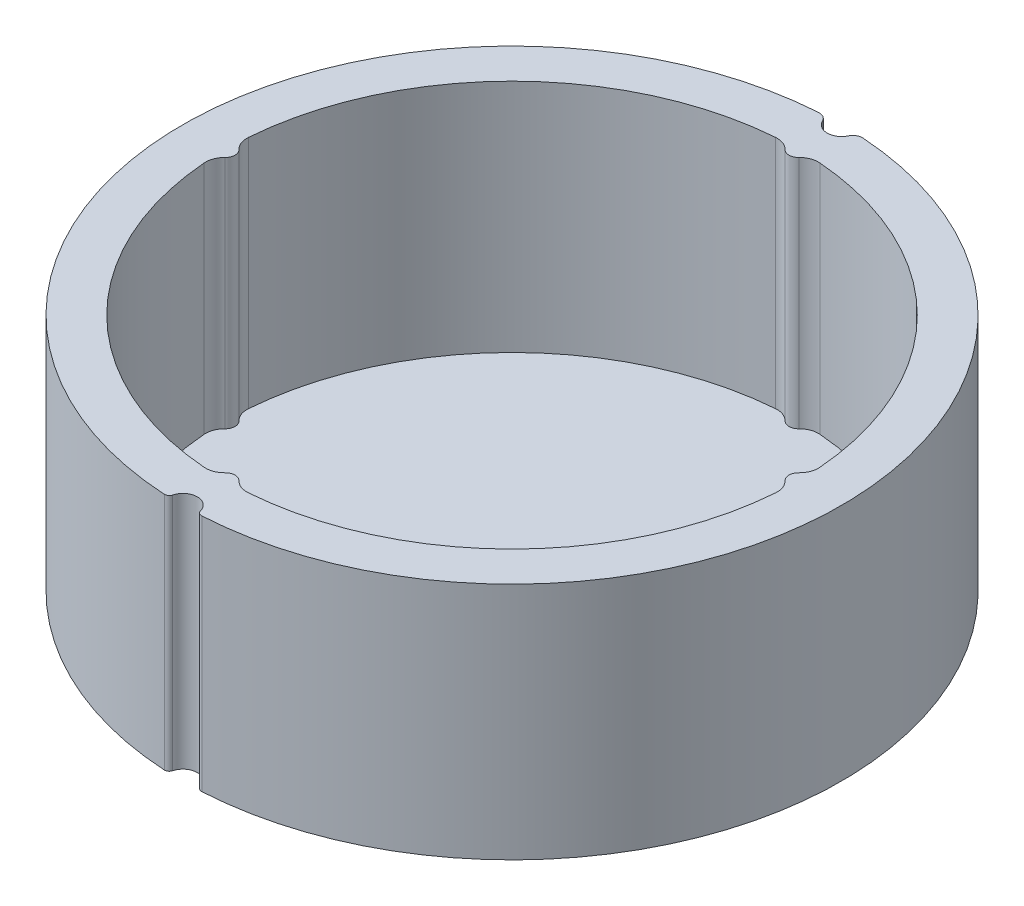
from build123d import *

# Parameters (mm, degrees)
BOSS_EXTRUDE1_DEPTH = 25
CUT_EXTRUDE2_DEPTH  = 55.786493398
BOSS_EXTRUDE2_DEPTH = 0.4


with BuildPart() as part:
    # Sketch1 → Boss-Extrude1 (new body)
    with BuildSketch(Plane(origin=(0, 0, 0), x_dir=(1, 0, 0), z_dir=(0, 1, 0))):
        with BuildLine():
            ThreePointArc((1.451818925, -34.068556857), (1.641248992, -34.346908706), (1.964225605, -34.442038138))
            ThreePointArc((1.964225605, -34.442038138), (26.591847487, -21.978073076), (34.198225299, 4.555174015))
            ThreePointArc((34.198225299, 4.555174015), (23.590291339, 25.176355888), (2.324135821, 34.423627607))
            ThreePointArc((2.324135821, 34.423627607), (1.751838249, 34.289058819), (1.354061739, 33.856153382))
            ThreePointArc((1.354061739, 33.856153382), (0, 33.001534515), (-1.354061739, 33.856153382))
            ThreePointArc((-1.354061739, 33.856153382), (-1.751838249, 34.289058819), (-2.324135821, 34.423627607))
            ThreePointArc((-2.324135821, 34.423627607), (-23.590291339, 25.176355888), (-34.198225299, 4.555174015))
            ThreePointArc((-34.198225299, 4.555174015), (-26.591847487, -21.978073076), (-1.964225605, -34.442038138))
            ThreePointArc((-1.964225605, -34.442038138), (-1.641248992, -34.346908706), (-1.451818925, -34.068556857))
            ThreePointArc((-1.451818925, -34.068556857), (0, -32.945679925), (1.451818925, -34.068556857))
        make_face()
        with BuildLine():
            Line((-2.417, 3.787737139), (0, 3.787737139))
            Line((0, 3.787737139), (2.417, 3.787737139))
            ThreePointArc((2.417, 3.787737139), (0, -4.489512172), (-2.417, 3.787737139))
        make_face(mode=Mode.SUBTRACT)
    extrude(amount=BOSS_EXTRUDE1_DEPTH)

    # Sketch2 → Cut-Extrude2 (cut, through all)
    with BuildSketch(Plane(origin=(0, 0, 0), x_dir=(1, 0, 0), z_dir=(0, 1, 0))):
        with BuildLine():
            ThreePointArc((-29.910714286, -2.312827473), (-21.213203436, -21.213203436), (-2.312827473, -29.910714286))
            ThreePointArc((-2.312827473, -29.910714286), (-1.448498888, -29.786346067), (-0.719546325, -29.305555556))
            ThreePointArc((-0.719546325, -29.305555556), (0, -29), (0.719546325, -29.305555556))
            ThreePointArc((0.719546325, -29.305555556), (1.448498888, -29.786346067), (2.312827473, -29.910714286))
            ThreePointArc((2.312827473, -29.910714286), (21.213203436, -21.213203436), (29.910714286, -2.312827473))
            ThreePointArc((29.910714286, -2.312827473), (29.786346067, -1.448498888), (29.305555556, -0.719546325))
            ThreePointArc((29.305555556, -0.719546325), (29, 0), (29.305555556, 0.719546325))
            ThreePointArc((29.305555556, 0.719546325), (29.786346067, 1.448498888), (29.910714286, 2.312827473))
            ThreePointArc((29.910714286, 2.312827473), (21.213203436, 21.213203436), (2.312827473, 29.910714286))
            ThreePointArc((2.312827473, 29.910714286), (1.448498888, 29.786346067), (0.719546325, 29.305555556))
            ThreePointArc((0.719546325, 29.305555556), (0, 29), (-0.719546325, 29.305555556))
            ThreePointArc((-0.719546325, 29.305555556), (-1.448498888, 29.786346067), (-2.312827473, 29.910714286))
            ThreePointArc((-2.312827473, 29.910714286), (-21.213203436, 21.213203436), (-29.910714286, 2.312827473))
            ThreePointArc((-29.910714286, 2.312827473), (-29.786346067, 1.448498888), (-29.305555556, 0.719546325))
            ThreePointArc((-29.305555556, 0.719546325), (-29, 0), (-29.305555556, -0.719546325))
            ThreePointArc((-29.305555556, -0.719546325), (-29.786346067, -1.448498888), (-29.910714286, -2.312827473))
        make_face()
    extrude(amount=CUT_EXTRUDE2_DEPTH, mode=Mode.SUBTRACT)

    # Sketch2_2 → Boss-Extrude2 (add)
    with BuildSketch(Plane(origin=(0, 0, 0), x_dir=(1, 0, 0), z_dir=(0, 1, 0))):
        with BuildLine():
            ThreePointArc((-29.910714286, -2.312827473), (-21.213203436, -21.213203436), (-2.312827473, -29.910714286))
            ThreePointArc((-2.312827473, -29.910714286), (-1.448498888, -29.786346067), (-0.719546325, -29.305555556))
            ThreePointArc((-0.719546325, -29.305555556), (0, -29), (0.719546325, -29.305555556))
            ThreePointArc((0.719546325, -29.305555556), (1.448498888, -29.786346067), (2.312827473, -29.910714286))
            ThreePointArc((2.312827473, -29.910714286), (21.213203436, -21.213203436), (29.910714286, -2.312827473))
            ThreePointArc((29.910714286, -2.312827473), (29.786346067, -1.448498888), (29.305555556, -0.719546325))
            ThreePointArc((29.305555556, -0.719546325), (29, 0), (29.305555556, 0.719546325))
            ThreePointArc((29.305555556, 0.719546325), (29.786346067, 1.448498888), (29.910714286, 2.312827473))
            ThreePointArc((29.910714286, 2.312827473), (21.213203436, 21.213203436), (2.312827473, 29.910714286))
            ThreePointArc((2.312827473, 29.910714286), (1.448498888, 29.786346067), (0.719546325, 29.305555556))
            ThreePointArc((0.719546325, 29.305555556), (0, 29), (-0.719546325, 29.305555556))
            ThreePointArc((-0.719546325, 29.305555556), (-1.448498888, 29.786346067), (-2.312827473, 29.910714286))
            ThreePointArc((-2.312827473, 29.910714286), (-21.213203436, 21.213203436), (-29.910714286, 2.312827473))
            ThreePointArc((-29.910714286, 2.312827473), (-29.786346067, 1.448498888), (-29.305555556, 0.719546325))
            ThreePointArc((-29.305555556, 0.719546325), (-29, 0), (-29.305555556, -0.719546325))
            ThreePointArc((-29.305555556, -0.719546325), (-29.786346067, -1.448498888), (-29.910714286, -2.312827473))
        make_face()
    extrude(amount=BOSS_EXTRUDE2_DEPTH)


solid = part.part
